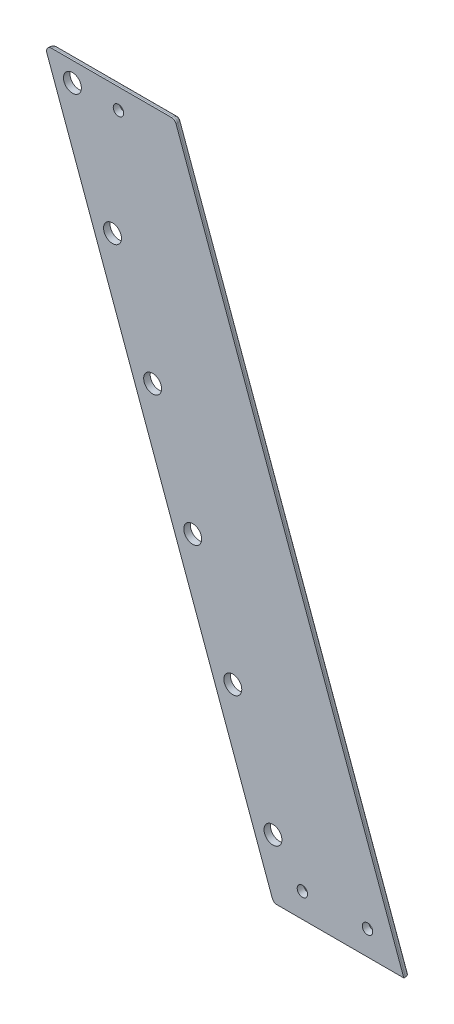
from build123d import *

# Parameters (mm, degrees)
SKETCH2_R           = 2.75
SKETCH2_R_2         = 1.6
BOSS_EXTRUDE1_DEPTH = 2
FILLET1_R           = 1.5


with BuildPart() as part:
    # Sketch2 → Boss-Extrude1 (new body)
    with BuildSketch(Plane.XY):
        Polygon((-13.676428112, 164.5), (-83.975339533, 357.644671741), (-124.00010851, 357.644671741), (-53.701197089, 164.5), align=None)
        with Locations((-78.493044991, 250.157868697)):
            Circle(SKETCH2_R, mode=Mode.SUBTRACT)
        with Locations((-53.867594671, 182.5)):
            Circle(SKETCH2_R, mode=Mode.SUBTRACT)
        with Locations((-66.180319831, 216.328934348)):
            Circle(SKETCH2_R, mode=Mode.SUBTRACT)
        with Locations((-44.822322699, 172)):
            Circle(SKETCH2_R_2, mode=Mode.SUBTRACT)
        with Locations((-24.822322699, 172)):
            Circle(SKETCH2_R_2, mode=Mode.SUBTRACT)
        with Locations((-90.805770151, 283.986803045)):
            Circle(SKETCH2_R, mode=Mode.SUBTRACT)
        with Locations((-103.11849531, 317.815737393)):
            Circle(SKETCH2_R, mode=Mode.SUBTRACT)
        with Locations((-115.43122047, 351.644671741)):
            Circle(SKETCH2_R, mode=Mode.SUBTRACT)
        with Locations((-101.29954666, 351.411510234)):
            Circle(SKETCH2_R_2, mode=Mode.SUBTRACT)
    extrude(amount=BOSS_EXTRUDE1_DEPTH)

    # Fillet1
    fillet1_edges = [part.edges().sort_by_distance(p)[0] for p in [
        (-88.8506528, 261.072335871, 0),
        (-103.987724022, 357.644671741, 0),
        (-48.825883822, 261.072335871, 0),
        (-53.701197089, 164.5, 1),
        (-124.00010851, 357.644671741, 1),
        (-83.975339533, 357.644671741, 1),
    ]]
    fillet(fillet1_edges, radius=FILLET1_R)


solid = part.part
